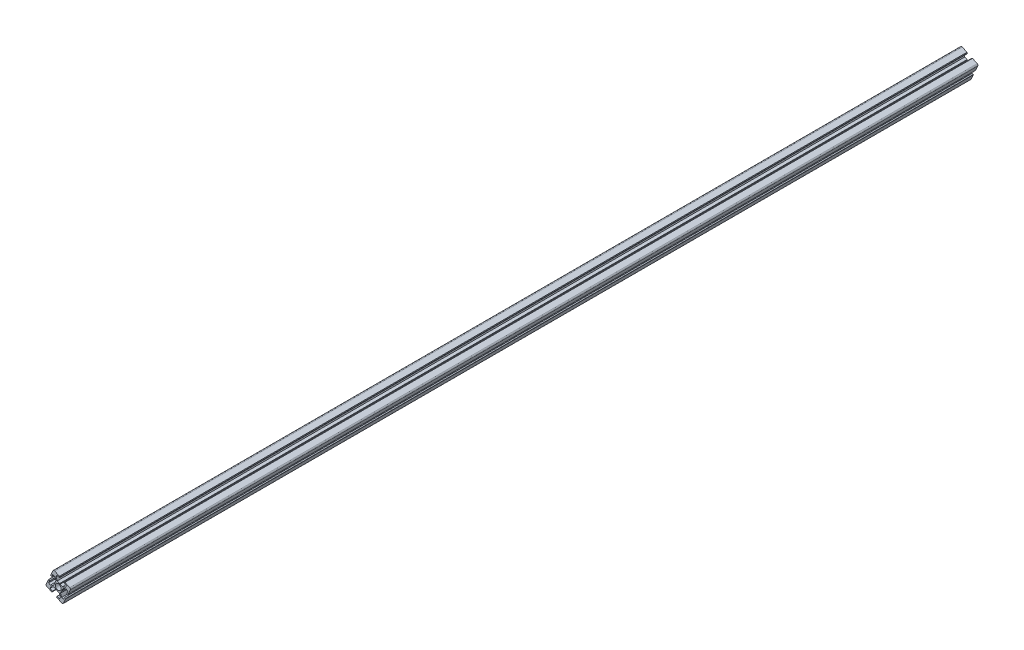
from build123d import *

# Parameters (mm, degrees)
BOSS_EXTRUDE1_DEPTH = 2000
SCALE1_SCALE        = 3
SKETCH2_R           = 115.047789556
CUT_EXTRUDE1_DEPTH  = 1600
SKETCH3_R           = 13.75
CUT_EXTRUDE2_DEPTH  = 4401
SCALE2_SCALE        = 0.466666667
CUT_EXTRUDE3_DEPTH  = 53.3


with BuildPart() as part:
    # Sketch1 → Boss-Extrude1 (new body)
    with BuildSketch(Plane.XY):
        with BuildLine():
            Line((-8.216270499, 18.069114507), (-11.842563011, 10.160890774))
            ThreePointArc((-11.842563011, 10.160890774), (-11.851111664, 9.931439908), (-11.694910211, 9.763148835))
            Line((-11.694910211, 9.763148835), (-10.149625113, 9.054562941))
            Line((-10.149625113, 9.054562941), (-8.37816038, 12.917775685))
            Line((-8.37816038, 12.917775685), (-5.345959751, 11.527369089))
            Line((-5.345959751, 11.527369089), (-3.542521768, 6.669331059))
            Line((-3.542521768, 6.669331059), (-5.237363855, 2.973217088))
            Line((-5.237363855, 2.973217088), (-5.181250032, 2.375846818))
            Line((-5.181250032, 2.375846818), (-5.67053095, 2.028565688))
            Line((-5.67053095, 2.028565688), (-7.365373037, -1.667548284))
            Line((-7.365373037, -1.667548284), (-12.223411067, -3.470986267))
            Line((-12.223411067, -3.470986267), (-15.255611696, -2.080579672))
            Line((-15.255611696, -2.080579672), (-13.484146963, 1.782633072))
            Line((-13.484146963, 1.782633072), (-15.029432061, 2.491218965))
            ThreePointArc((-15.029432061, 2.491218965), (-15.258882927, 2.499767617), (-15.427174, 2.343566164))
            Line((-15.427174, 2.343566164), (-19.053466512, -5.564657569))
            ThreePointArc((-19.053466512, -5.564657569), (-19.110457529, -7.094330009), (-18.069114507, -8.216270499))
            Line((-18.069114507, -8.216270499), (-10.160890774, -11.842563011))
            ThreePointArc((-10.160890774, -11.842563011), (-9.931439908, -11.851111664), (-9.763148835, -11.694910211))
            Line((-9.763148835, -11.694910211), (-9.054562941, -10.149625113))
            Line((-9.054562941, -10.149625113), (-12.917775685, -8.37816038))
            Line((-12.917775685, -8.37816038), (-11.527369089, -5.345959751))
            Line((-11.527369089, -5.345959751), (-6.669331059, -3.542521768))
            Line((-6.669331059, -3.542521768), (-2.973217088, -5.237363855))
            Line((-2.973217088, -5.237363855), (-2.375846818, -5.181250032))
            Line((-2.375846818, -5.181250032), (-2.028565688, -5.67053095))
            Line((-2.028565688, -5.67053095), (1.667548284, -7.365373037))
            Line((1.667548284, -7.365373037), (3.470986267, -12.223411067))
            Line((3.470986267, -12.223411067), (2.080579672, -15.255611696))
            Line((2.080579672, -15.255611696), (-1.782633072, -13.484146963))
            Line((-1.782633072, -13.484146963), (-2.491218965, -15.029432061))
            ThreePointArc((-2.491218965, -15.029432061), (-2.499767617, -15.258882927), (-2.343566164, -15.427174))
            Line((-2.343566164, -15.427174), (5.564657569, -19.053466512))
            ThreePointArc((5.564657569, -19.053466512), (7.094330009, -19.110457529), (8.216270499, -18.069114507))
            Line((8.216270499, -18.069114507), (11.842563011, -10.160890774))
            ThreePointArc((11.842563011, -10.160890774), (11.851111664, -9.931439908), (11.694910211, -9.763148835))
            Line((11.694910211, -9.763148835), (10.149625113, -9.054562941))
            Line((10.149625113, -9.054562941), (8.37816038, -12.917775685))
            Line((8.37816038, -12.917775685), (5.345959751, -11.527369089))
            Line((5.345959751, -11.527369089), (3.542521768, -6.669331059))
            Line((3.542521768, -6.669331059), (5.237363855, -2.973217088))
            Line((5.237363855, -2.973217088), (5.181250032, -2.375846818))
            Line((5.181250032, -2.375846818), (5.67053095, -2.028565688))
            Line((5.67053095, -2.028565688), (7.365373037, 1.667548284))
            Line((7.365373037, 1.667548284), (12.223411067, 3.470986267))
            Line((12.223411067, 3.470986267), (15.255611696, 2.080579672))
            Line((15.255611696, 2.080579672), (13.484146963, -1.782633072))
            Line((13.484146963, -1.782633072), (15.029432061, -2.491218965))
            ThreePointArc((15.029432061, -2.491218965), (15.258882927, -2.499767617), (15.427174, -2.343566164))
            Line((15.427174, -2.343566164), (19.053466512, 5.564657569))
            ThreePointArc((19.053466512, 5.564657569), (19.110457529, 7.094330009), (18.069114507, 8.216270499))
            Line((18.069114507, 8.216270499), (10.597022809, 11.642575962))
            Line((10.597022809, 11.642575962), (9.413078742, 11.203063202))
            Line((9.413078742, 11.203063202), (8.951663933, 10.196809148))
            Line((8.951663933, 10.196809148), (12.917775685, 8.37816038))
            Line((12.917775685, 8.37816038), (11.527369089, 5.345959751))
            Line((11.527369089, 5.345959751), (6.669331059, 3.542521768))
            Line((6.669331059, 3.542521768), (2.973217088, 5.237363855))
            Line((2.973217088, 5.237363855), (2.375846818, 5.181250032))
            Line((2.375846818, 5.181250032), (2.028565688, 5.67053095))
            Line((2.028565688, 5.67053095), (-1.667548284, 7.365373037))
            Line((-1.667548284, 7.365373037), (-3.470986267, 12.223411067))
            Line((-3.470986267, 12.223411067), (-2.080579672, 15.255611696))
            Line((-2.080579672, 15.255611696), (1.88553208, 13.436962929))
            Line((1.88553208, 13.436962929), (2.346946889, 14.443216983))
            Line((2.346946889, 14.443216983), (1.907434129, 15.62716105))
            Line((1.907434129, 15.62716105), (-5.564657569, 19.053466512))
            ThreePointArc((-5.564657569, 19.053466512), (-7.094330009, 19.110457529), (-8.216270499, 18.069114507))
        make_face()
    extrude(amount=BOSS_EXTRUDE1_DEPTH)


with BuildPart() as part_1:
    # Scale1: scaled about (-0.00473582, -0.010327884, 1000)
    add(part.part.scale(SCALE1_SCALE).moved(Location((0.00947164, 0.020655768, -2000))))

    # Sketch2 → Cut-Extrude1 (cut)
    with BuildSketch(Plane(origin=(0, 0, -2000), x_dir=(-1, 0, 0), z_dir=(0, 0, -1))):
        Circle(SKETCH2_R)
    extrude(amount=-CUT_EXTRUDE1_DEPTH, mode=Mode.SUBTRACT)

    # Sketch3 → Cut-Extrude2 (cut, through all)
    with BuildSketch(Plane.XY.offset(4000)):
        Circle(SKETCH3_R)
    extrude(amount=-CUT_EXTRUDE2_DEPTH, mode=Mode.SUBTRACT)


with BuildPart() as part_2:
    # Scale2: scaled about (-0.005610815, -0.012236071, 1800)
    add(part_1.part.scale(SCALE2_SCALE).moved(Location((-0.002992435, -0.006525905, 960))))

    # Sketch6 → Cut-Extrude3 (cut)
    with BuildSketch(Plane(origin=(0, 0, 773.333333333), x_dir=(-1, 0, 0), z_dir=(0, 0, -1))):
        with BuildLine():
            Line((7.789092932, 26.67796657), (-2.671835446, 21.881138923))
            Line((-2.671835446, 21.881138923), (-3.287153309, 20.223617229))
            Line((-3.287153309, 20.223617229), (-2.641172576, 18.814861553))
            Line((-2.641172576, 18.814861553), (2.911383876, 21.360969828))
            Line((2.911383876, 21.360969828), (4.857953109, 17.115888947))
            Line((4.857953109, 17.115888947), (2.333139933, 10.314635704))
            Line((2.333139933, 10.314635704), (-2.841419627, 7.941856782))
            Line((-2.841419627, 7.941856782), (-3.32761321, 7.256863498))
            Line((-3.32761321, 7.256863498), (-4.163931587, 7.33542285))
            Line((-4.163931587, 7.33542285), (-9.338491147, 4.962643928))
            Line((-9.338491147, 4.962643928), (-16.13974439, 7.487457104))
            Line((-16.13974439, 7.487457104), (-18.086313623, 11.732537985))
            Line((-18.086313623, 11.732537985), (-12.533757171, 14.27864626))
            Line((-12.533757171, 14.27864626), (-13.179737904, 15.687401936))
            Line((-13.179737904, 15.687401936), (-14.837259597, 16.302719799))
            Line((-14.837259597, 16.302719799), (-25.298187975, 11.505892152))
            ThreePointArc((-25.298187975, 11.505892152), (-26.756068205, 9.935175466), (-26.676280782, 7.79363405))
            Line((-26.676280782, 7.79363405), (-21.599471265, -3.277879177))
            ThreePointArc((-21.599471265, -3.277879177), (-21.363863762, -3.496561211), (-21.04263255, -3.484593098))
            Line((-21.04263255, -3.484593098), (-18.879233413, -2.492572848))
            Line((-18.879233413, -2.492572848), (-21.359284039, 2.915924993))
            Line((-21.359284039, 2.915924993), (-17.114203158, 4.862494227))
            Line((-17.114203158, 4.862494227), (-10.312949916, 2.33768105))
            Line((-10.312949916, 2.33768105), (-7.940170994, -2.83687851))
            Line((-7.940170994, -2.83687851), (-7.25517771, -3.323072093))
            Line((-7.25517771, -3.323072093), (-7.333737061, -4.15939047))
            Line((-7.333737061, -4.15939047), (-4.960958139, -9.33395003))
            Line((-4.960958139, -9.33395003), (-7.485771316, -16.135203272))
            Line((-7.485771316, -16.135203272), (-11.730852197, -18.081772506))
            Line((-11.730852197, -18.081772506), (-14.210902823, -12.673274665))
            Line((-14.210902823, -12.673274665), (-16.374301959, -13.665294916))
            ThreePointArc((-16.374301959, -13.665294916), (-16.592983994, -13.900902418), (-16.58101588, -14.222133631))
            Line((-16.58101588, -14.222133631), (-11.504206363, -25.293646858))
            ThreePointArc((-11.504206363, -25.293646858), (-9.933489678, -26.751527087), (-7.791948261, -26.671739664))
            Line((-7.791948261, -26.671739664), (3.279564965, -21.594930148))
            ThreePointArc((3.279564965, -21.594930148), (3.498247, -21.359322645), (3.486278886, -21.038091432))
            Line((3.486278886, -21.038091432), (2.494258636, -18.874692296))
            Line((2.494258636, -18.874692296), (-2.914239205, -21.354742922))
            Line((-2.914239205, -21.354742922), (-4.860808438, -17.109662041))
            Line((-4.860808438, -17.109662041), (-2.335995262, -10.308408799))
            Line((-2.335995262, -10.308408799), (2.838564298, -7.935629877))
            Line((2.838564298, -7.935629877), (3.324757881, -7.250636592))
            Line((3.324757881, -7.250636592), (4.161076258, -7.329195944))
            Line((4.161076258, -7.329195944), (9.335635818, -4.956417022))
            Line((9.335635818, -4.956417022), (16.13688906, -7.481230198))
            Line((16.13688906, -7.481230198), (18.083458294, -11.72631108))
            Line((18.083458294, -11.72631108), (12.674960453, -14.206361706))
            Line((12.674960453, -14.206361706), (13.666980704, -16.369760842))
            ThreePointArc((13.666980704, -16.369760842), (13.902588207, -16.588442876), (14.223819419, -16.576474763))
            Line((14.223819419, -16.576474763), (25.295332646, -11.499665246))
            ThreePointArc((25.295332646, -11.499665246), (26.753212876, -9.92894856), (26.673425453, -7.787407144))
            Line((26.673425453, -7.787407144), (21.596615936, 3.284106083))
            ThreePointArc((21.596615936, 3.284106083), (21.361008433, 3.502788117), (21.039777221, 3.490820004))
            Line((21.039777221, 3.490820004), (18.876378084, 2.498799753))
            Line((18.876378084, 2.498799753), (21.35642871, -2.909698087))
            Line((21.35642871, -2.909698087), (17.111347829, -4.856267321))
            Line((17.111347829, -4.856267321), (10.310094587, -2.331454145))
            Line((10.310094587, -2.331454145), (7.937315665, 2.843105415))
            Line((7.937315665, 2.843105415), (7.252322381, 3.329298998))
            Line((7.252322381, 3.329298998), (7.330881732, 4.165617376))
            Line((7.330881732, 4.165617376), (4.95810281, 9.340176936))
            Line((4.95810281, 9.340176936), (7.482915987, 16.141430178))
            Line((7.482915987, 16.141430178), (11.727996868, 18.087999412))
            Line((11.727996868, 18.087999412), (14.208047494, 12.679501571))
            Line((14.208047494, 12.679501571), (16.37144663, 13.671521821))
            ThreePointArc((16.37144663, 13.671521821), (16.590128665, 13.907129324), (16.578160551, 14.228360537))
            Line((16.578160551, 14.228360537), (11.501351034, 25.299873763))
            ThreePointArc((11.501351034, 25.299873763), (9.930634349, 26.757753993), (7.789092932, 26.67796657))
        make_face()
    extrude(amount=-CUT_EXTRUDE3_DEPTH, mode=Mode.SUBTRACT)


solid = part_2.part
